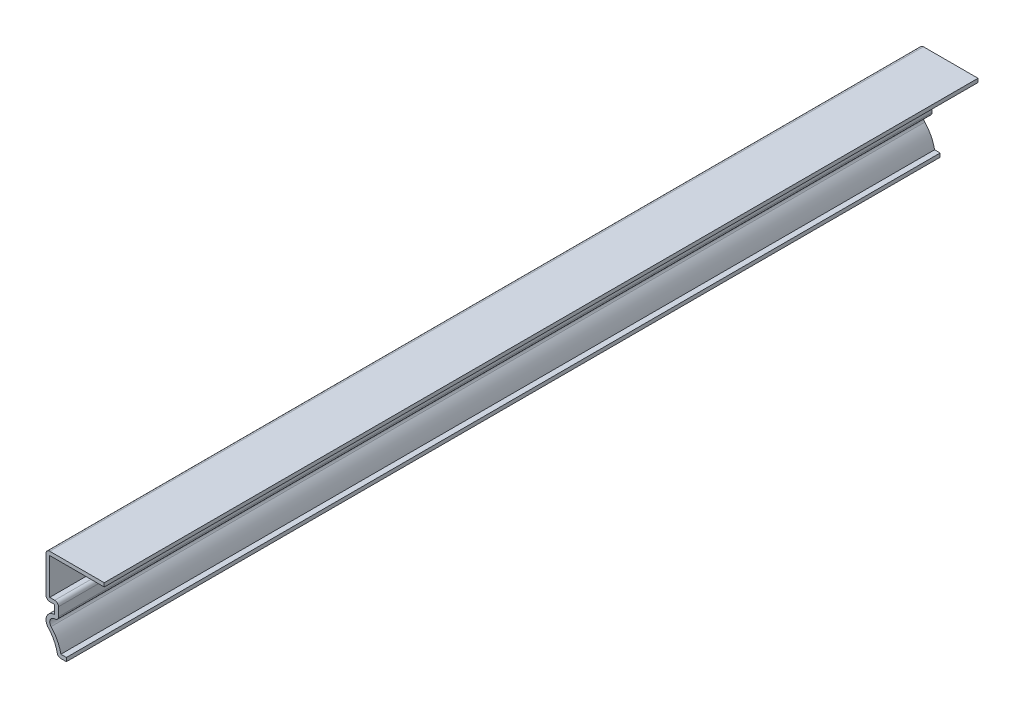
from build123d import *

# Parameters (mm, degrees)
EXTRUDE_THIN1_DEPTH = 238.125
FILLET1_R           = 1.016


with BuildPart() as part:
    # Sketch1 → Extrude-Thin1 (new body)
    with BuildSketch(Plane.XY):
        with BuildLine():
            Line((0, 23.8125), (-15.875, 23.8125))
            Line((-15.875, 23.8125), (-15.875, 11.90625))
            Line((-15.875, 11.90625), (-13.49375, 11.90625))
            Line((-13.49375, 11.90625), (-13.49375, 9.525))
            ThreePointArc((-13.49375, 9.525), (-15.679243133, 8.08925057), (-15.229296459, 5.51334206))
            ThreePointArc((-15.229296459, 5.51334206), (-13.514036913, 2.963393123), (-12.7, 0))
            Line((-12.7, 0), (-10.31875, 0))
            Line((-10.31875, 0), (-10.31875, 1.016))
            Line((-10.31875, 1.016), (-11.826680113, 1.016))
            ThreePointArc((-11.826680113, 1.016), (-12.791218599, 3.800383088), (-14.488796637, 6.208982781))
            ThreePointArc((-14.488796637, 6.208982781), (-14.417167703, 8.149338041), (-12.47775, 8.05569932))
            Line((-12.47775, 8.05569932), (-12.47775, 12.92225))
            Line((-12.47775, 12.92225), (-14.859, 12.92225))
            Line((-14.859, 12.92225), (-14.859, 22.7965))
            Line((-14.859, 22.7965), (0, 22.7965))
            Line((0, 22.7965), (0, 23.8125))
        make_face()
    extrude(amount=-EXTRUDE_THIN1_DEPTH)

    # Fillet1
    fillet1_edges = [part.edges().sort_by_distance(p)[0] for p in [
        (-12.47775, 12.92225, -119.0625),
        (-12.47775, 8.05569932, -119.0625),
        (-12.7, 0, -119.0625),
        (-15.875, 11.90625, -119.0625),
        (-15.875, 23.8125, -119.0625),
    ]]
    fillet(fillet1_edges, radius=FILLET1_R)


solid = part.part
